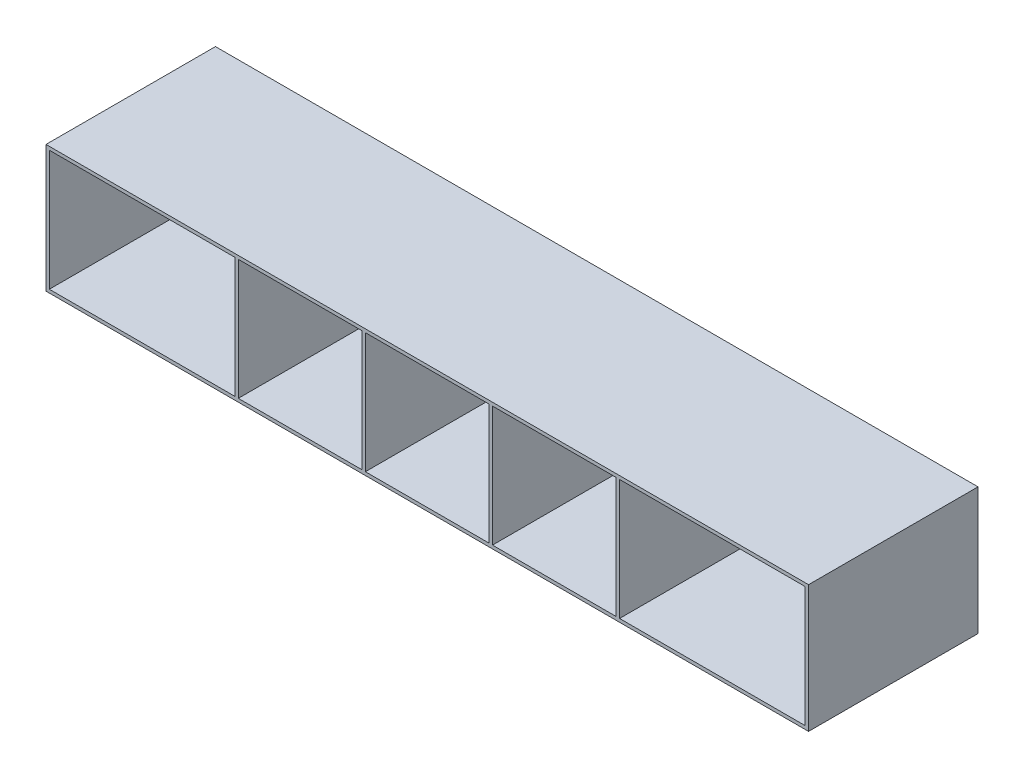
from build123d import *

# Parameters (mm, degrees)
SKETCH_3_W          = 457.2
SKETCH_3_H          = 76.2
EXTRUDE_4_DEPTH     = 101.6
SKETCH_3_3_W        = 111.3
SKETCH_3_3_H        = 72.2
SKETCH_3_3_W_2      = 74.2
CUT_EXTRUDE_2_DEPTH = 254.045707334


with BuildPart() as part:
    # Эскиз3 → Бобышка-Вытянуть4 (new body)
    with BuildSketch(Plane.XY):
        Rectangle(SKETCH_3_W, SKETCH_3_H)
    extrude(amount=EXTRUDE_4_DEPTH)

    # Эскиз3<3> → Вырез-Вытянуть2 (cut, through all)
    with BuildSketch(Plane.XY):
        with Locations((-170.95, 0)):
            Rectangle(SKETCH_3_3_W, SKETCH_3_3_H)
        with Locations((-76.2, 0)):
            Rectangle(SKETCH_3_3_W_2, SKETCH_3_3_H)
        Rectangle(SKETCH_3_3_W_2, SKETCH_3_3_H)
        with Locations((76.2, 0)):
            Rectangle(SKETCH_3_3_W_2, SKETCH_3_3_H)
        with Locations((170.95, 0)):
            Rectangle(SKETCH_3_3_W, SKETCH_3_3_H)
    extrude(amount=CUT_EXTRUDE_2_DEPTH, mode=Mode.SUBTRACT)


solid = part.part
